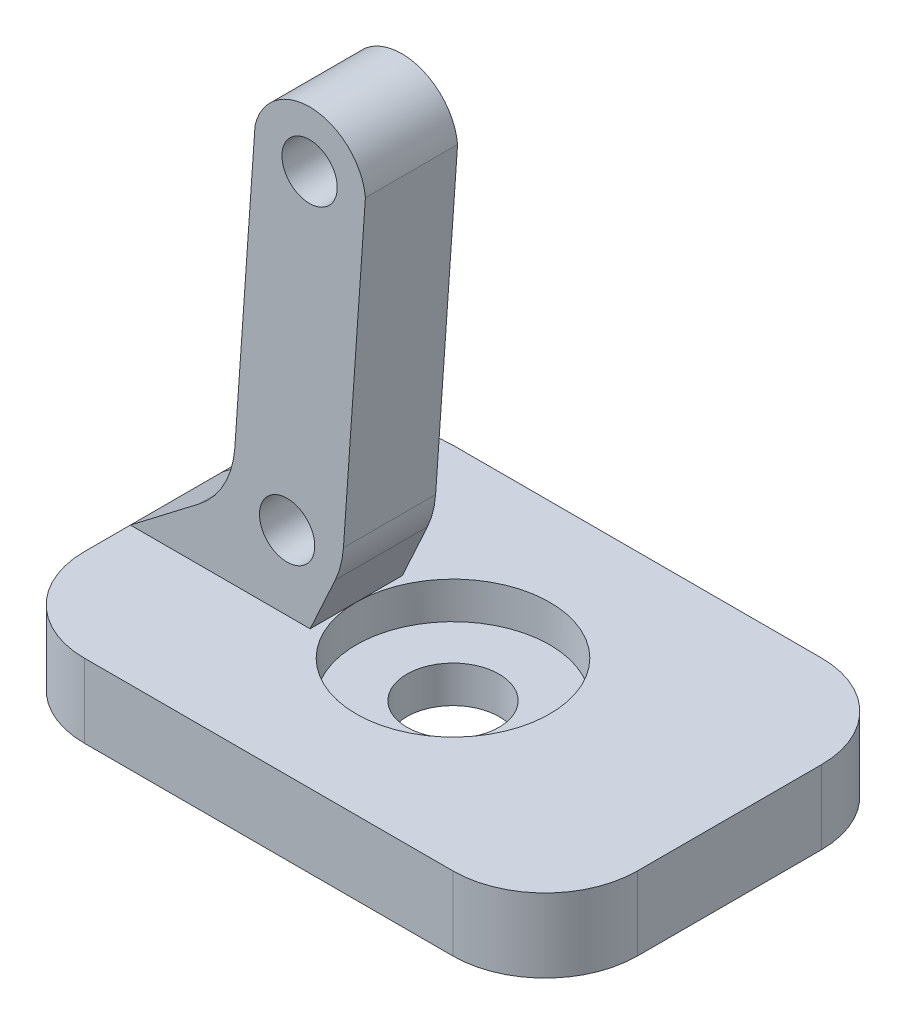
from build123d import *

# Parameters (mm, degrees)
SKETCH1_W           = 30
SKETCH1_H           = 20
BOSS_EXTRUDE1_DEPTH = 4
SKETCH2_R           = 5.25
CUT_EXTRUDE1_DEPTH  = 2
SKETCH3_R           = 2.5
CUT_EXTRUDE2_DEPTH  = 5
SKETCH4_R           = 1.5
BOSS_EXTRUDE2_DEPTH = 2.5
FILLET1_R           = 5
FILLET2_R           = 5


with BuildPart() as part:
    # Sketch1 → Boss-Extrude1 (new body)
    with BuildSketch(Plane(origin=(0, 0, 0), x_dir=(1, 0, 0), z_dir=(0, 1, 0))):
        Rectangle(SKETCH1_W, SKETCH1_H)
    extrude(amount=BOSS_EXTRUDE1_DEPTH)

    # Sketch2 → Cut-Extrude1 (cut)
    with BuildSketch(Plane(origin=(0, 4, 0), x_dir=(1, 0, 0), z_dir=(0, 1, 0))):
        Circle(SKETCH2_R)
    extrude(amount=-CUT_EXTRUDE1_DEPTH, mode=Mode.SUBTRACT)

    # Sketch3 → Cut-Extrude2 (cut, through all)
    with BuildSketch(Plane(origin=(0, 4, 0), x_dir=(1, 0, 0), z_dir=(0, 1, 0))):
        Circle(SKETCH3_R)
    extrude(amount=-CUT_EXTRUDE2_DEPTH, mode=Mode.SUBTRACT)

    # Sketch4 → Boss-Extrude2 (add, symmetric)
    with BuildSketch(Plane.XY):
        with BuildLine():
            Line((-15, 4), (-9.492692151, 8.218800623))
            Line((-9.492692151, 8.218800623), (-8.237245547, 26.172523512))
            ThreePointArc((-8.237245547, 26.172523512), (-5.067133546, 28.50047615), (-2.251861245, 25.75398467))
            Line((-2.251861245, 25.75398467), (-3.507307849, 7.800261781))
            Line((-3.507307849, 7.800261781), (-5.25, 4))
            Line((-5.25, 4), (-15, 4))
        make_face()
        with Locations((-6.5, 8.009531202)):
            Circle(SKETCH4_R, mode=Mode.SUBTRACT)
        with Locations((-5.279261709, 25.466902082)):
            Circle(SKETCH4_R, mode=Mode.SUBTRACT)
    extrude(amount=BOSS_EXTRUDE2_DEPTH, both=True)

    # Fillet1
    fillet1_edges = [part.edges().sort_by_distance(p)[0] for p in [
        (-9.492692151, 8.218800623, 0),
        (-3.507307849, 7.800261781, 0),
    ]]
    fillet(fillet1_edges, radius=FILLET1_R)

    # Fillet2
    fillet2_edges = [part.edges().sort_by_distance(p)[0] for p in [
        (15, 2, 10),
        (-15, 2, 10),
        (-15, 2, -10),
        (15, 2, -10),
    ]]
    fillet(fillet2_edges, radius=FILLET2_R)


solid = part.part
